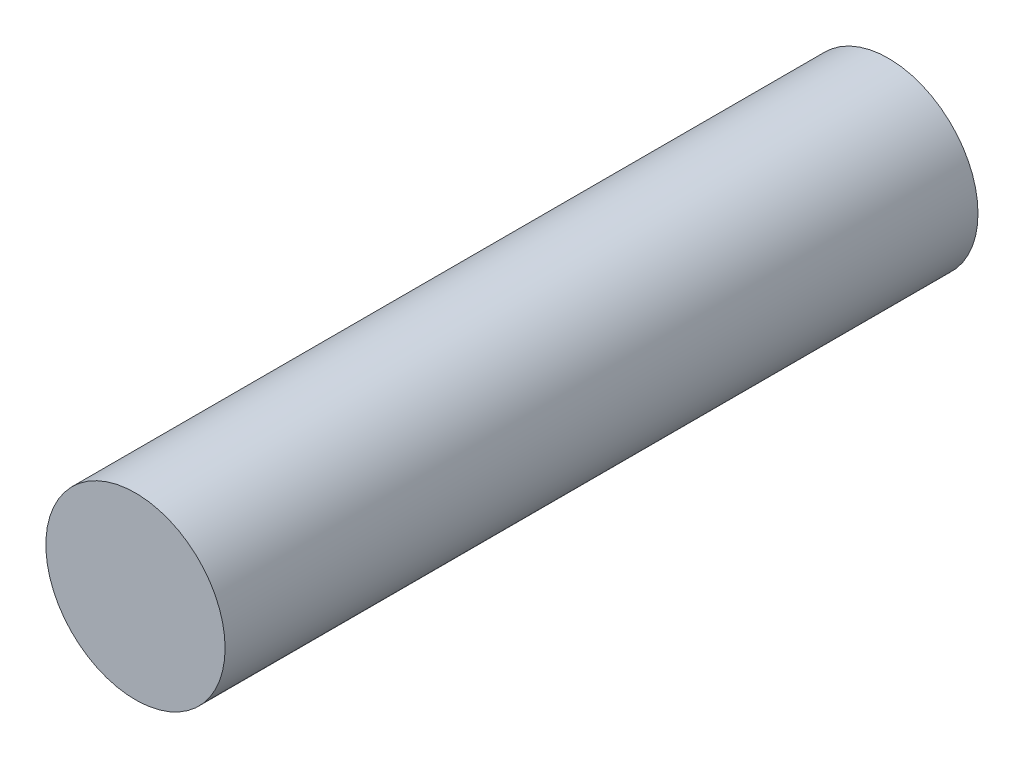
from build123d import *

# Parameters (mm, degrees)
SKETCH1_R           = 7.5
BOSS_EXTRUDE1_DEPTH = 31.5


with BuildPart() as part:
    # Sketch1 → Boss-Extrude1 (new body, symmetric)
    with BuildSketch(Plane.XY):
        Circle(SKETCH1_R)
    extrude(amount=BOSS_EXTRUDE1_DEPTH, both=True)


solid = part.part
